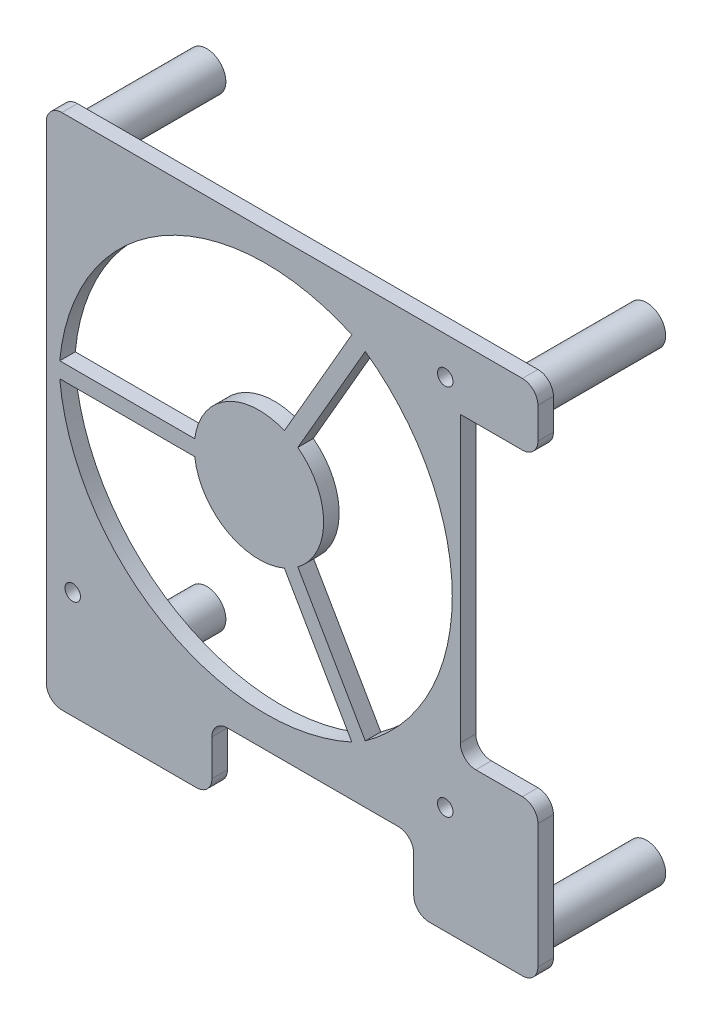
from build123d import *

# Parameters (mm, degrees)
SALIENTE_EXTRUIR1_DEPTH = 3
CROQUIS2_R              = 3.7
CROQUIS2_R_2            = 1.5
SALIENTE_EXTRUIR2_DEPTH = 23
CROQUIS3_R              = 1.5
CORTAR_EXTRUIR1_DEPTH   = 3


with BuildPart() as part:
    # Croquis1 → Saliente-Extruir1 (new body)
    with BuildSketch(Plane.XY):
        with BuildLine():
            Line((-194.10496046, 92.470884256), (-194.10496046, 88.470884256))
            Line((-194.10496046, 88.470884256), (-194.10496046, 5.382772077))
            Line((-194.10496046, 5.382772077), (-194.10496046, -1.529115744))
            ThreePointArc((-194.10496046, -1.529115744), (-193.226280804, -3.650436088), (-191.10496046, -4.529115744))
            Line((-191.10496046, -4.529115744), (-165.10496046, -4.529115744))
            ThreePointArc((-165.10496046, -4.529115744), (-162.983640117, -3.650436088), (-162.10496046, -1.529115744))
            Line((-162.10496046, -1.529115744), (-162.10496046, 5.470884256))
            ThreePointArc((-162.10496046, 5.470884256), (-161.226280804, 7.592204599), (-159.10496046, 8.470884256))
            Line((-159.10496046, 8.470884256), (-126.10496046, 8.470884256))
            ThreePointArc((-126.10496046, 8.470884256), (-123.983640117, 7.592204599), (-123.10496046, 5.470884256))
            Line((-123.10496046, 5.470884256), (-123.10496046, -1.529115744))
            ThreePointArc((-123.10496046, -1.529115744), (-122.226280804, -3.650436088), (-120.10496046, -4.529115744))
            Line((-120.10496046, -4.529115744), (-102.10496046, -4.529115744))
            ThreePointArc((-102.10496046, -4.529115744), (-99.983640117, -3.650436088), (-99.10496046, -1.529115744))
            Line((-99.10496046, -1.529115744), (-99.10496046, 22.470884256))
            ThreePointArc((-99.10496046, 22.470884256), (-99.983640117, 24.592204599), (-102.10496046, 25.470884256))
            Line((-102.10496046, 25.470884256), (-111.10496046, 25.470884256))
            ThreePointArc((-111.10496046, 25.470884256), (-113.226280804, 26.349563912), (-114.10496046, 28.470884256))
            Line((-114.10496046, 28.470884256), (-114.10496046, 60.470884256))
            Line((-114.10496046, 60.470884256), (-114.10496046, 83.470884256))
            Line((-114.10496046, 83.470884256), (-102.10496046, 83.470884256))
            ThreePointArc((-102.10496046, 83.470884256), (-99.983640117, 84.349563912), (-99.10496046, 86.470884256))
            Line((-99.10496046, 86.470884256), (-99.10496046, 92.470884256))
            ThreePointArc((-99.10496046, 92.470884256), (-99.983640117, 94.592204599), (-102.10496046, 95.470884256))
            Line((-102.10496046, 95.470884256), (-191.10496046, 95.470884256))
            ThreePointArc((-191.10496046, 95.470884256), (-193.226280804, 94.592204599), (-194.10496046, 92.470884256))
        make_face()
        with BuildLine():
            Line((-181.973694619, 53.715677144), (-191.512513703, 53.715677144))
            ThreePointArc((-191.512513703, 53.715677144), (-171.693012047, 84.571249386), (-135.061551809, 86.307655189))
            Line((-135.061551809, 86.307655189), (-139.830961352, 78.04679554))
            Line((-139.830961352, 78.04679554), (-148.106714986, 63.712769774))
            ThreePointArc((-148.106714986, 63.712769774), (-159.262513703, 63.040994691), (-165.422187349, 53.715677144))
            Line((-165.422187349, 53.715677144), (-181.973694619, 53.715677144))
        make_face(mode=Mode.SUBTRACT)
        with BuildLine():
            Line((-145.508638775, 62.212769774), (-137.23288514, 76.54679554))
            Line((-137.23288514, 76.54679554), (-132.463475598, 84.807655189))
            ThreePointArc((-132.463475598, 84.807655189), (-115.651517015, 52.215677144), (-132.463475598, 19.623699098))
            Line((-132.463475598, 19.623699098), (-137.23288514, 27.884558748))
            Line((-137.23288514, 27.884558748), (-145.508638775, 42.218584514))
            ThreePointArc((-145.508638775, 42.218584514), (-140.512513703, 52.215677144), (-145.508638775, 62.212769774))
        make_face(mode=Mode.SUBTRACT)
        with BuildLine():
            Line((-148.106714986, 40.718584514), (-139.830961352, 26.384558748))
            Line((-139.830961352, 26.384558748), (-135.061551809, 18.123699098))
            ThreePointArc((-135.061551809, 18.123699098), (-171.693012047, 19.860104901), (-191.512513703, 50.715677144))
            Line((-191.512513703, 50.715677144), (-181.973694619, 50.715677144))
            Line((-181.973694619, 50.715677144), (-165.422187349, 50.715677144))
            ThreePointArc((-165.422187349, 50.715677144), (-159.262513703, 41.390359596), (-148.106714986, 40.718584514))
        make_face(mode=Mode.SUBTRACT)
    extrude(amount=SALIENTE_EXTRUIR1_DEPTH)

    # Croquis2 → Saliente-Extruir2 (add)
    with BuildSketch(Plane(origin=(0, 0, 0), x_dir=(-1, 0, 0), z_dir=(0, 0, -1))):
        with Locations((189.10496046, 90.470884256)):
            Circle(CROQUIS2_R)
        with Locations((189.10496046, 90.470884256)):
            Circle(CROQUIS2_R_2, mode=Mode.SUBTRACT)
        with Locations((104.10496046, 90.470884256)):
            Circle(CROQUIS2_R)
        with Locations((104.10496046, 90.470884256)):
            Circle(CROQUIS2_R_2, mode=Mode.SUBTRACT)
        with Locations((104.10496046, 0.470884256)):
            Circle(CROQUIS2_R)
        with Locations((104.10496046, 0.470884256)):
            Circle(CROQUIS2_R_2, mode=Mode.SUBTRACT)
        with Locations((189.10496046, 0.470884256)):
            Circle(CROQUIS2_R)
        with Locations((189.10496046, 0.470884256)):
            Circle(CROQUIS2_R_2, mode=Mode.SUBTRACT)
    extrude(amount=SALIENTE_EXTRUIR2_DEPTH)

    # Croquis3 → Cortar-Extruir1 (cut)
    with BuildSketch(Plane.XY.offset(3)):
        with Locations((-117.012513703, 16.215677144)):
            Circle(CROQUIS3_R)
        with Locations((-189.012513703, 16.215677144)):
            Circle(CROQUIS3_R)
        with Locations((-117.012513703, 88.215677144)):
            Circle(CROQUIS3_R)
    extrude(amount=-CORTAR_EXTRUIR1_DEPTH, mode=Mode.SUBTRACT)


solid = part.part
